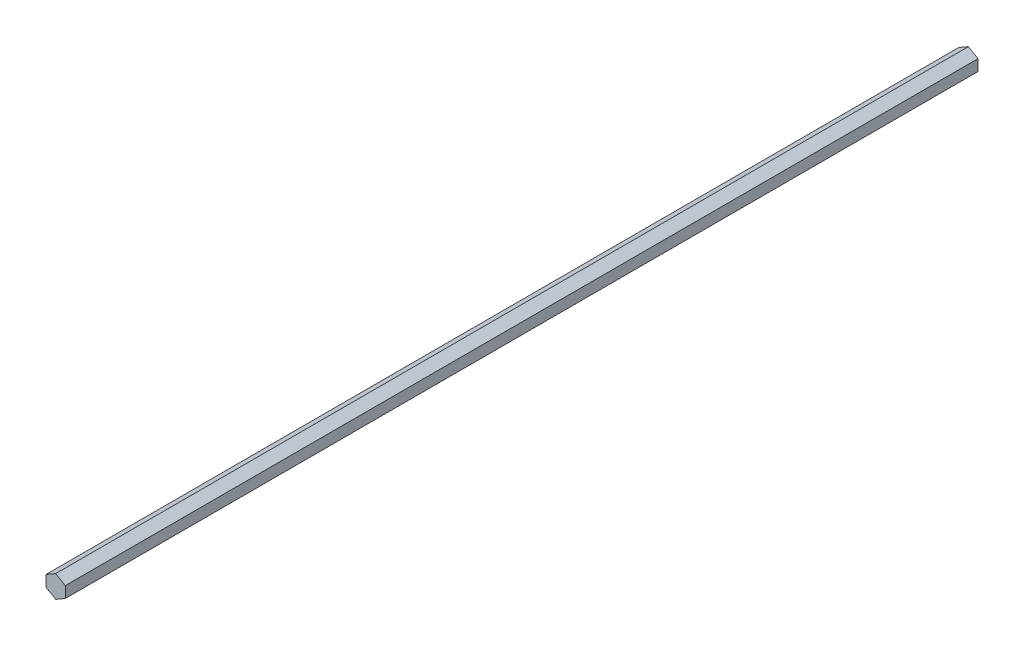
from build123d import *

# Parameters (mm, degrees)
EXTRUDE_1_DEPTH = 450


with BuildPart() as part:
    # 草图1 → 凸台-拉伸1 (new body)
    with BuildSketch(Plane.XY):
        Polygon((0, -5.5), (4.763139721, -2.75), (4.763139721, 2.75), (0, 5.5), (-4.763139721, 2.75), (-4.763139721, -2.75), align=None)
    extrude(amount=EXTRUDE_1_DEPTH)


solid = part.part
